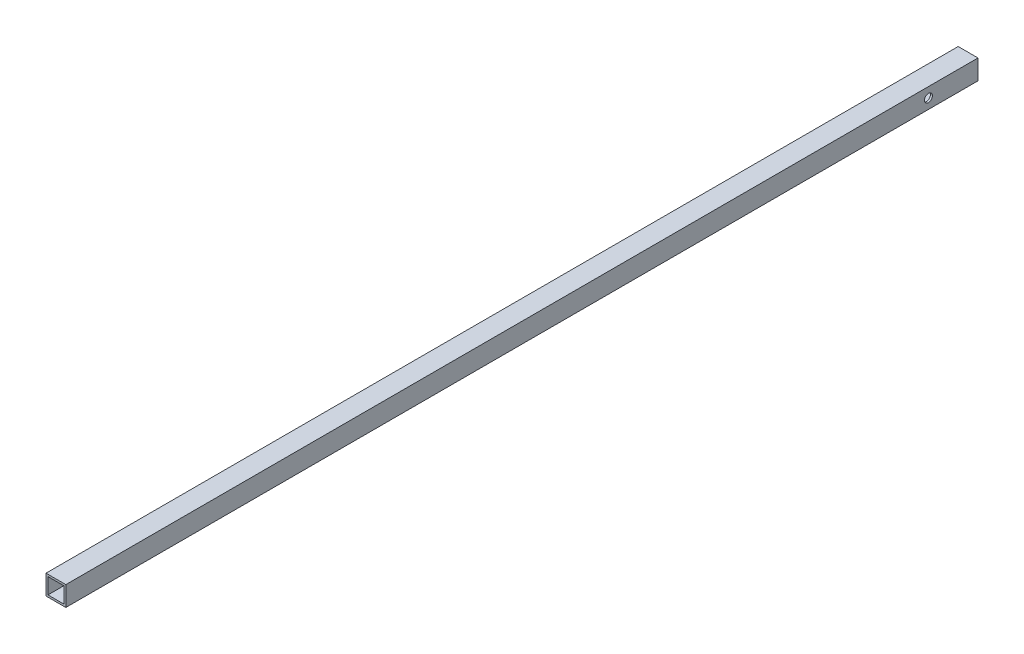
from build123d import *

# Parameters (mm, degrees)
SKETCH_1_W               = 20
SKETCH_1_H               = 20
SKETCH_1_W_2             = 16
SKETCH_1_H_2             = 16
EXTRUDE_1_DEPTH          = 970
SKETCH_2_R               = 4.05
CUT_EXTRUDE_1_DEPTH      = 970
SKETCH_4_W               = 21.376287738
SKETCH_4_H               = 29.089038522
CUT_EXTRUDE_3_DEPTH      = 50
SKETCH_6_R               = 1
CUT_EXTRUDE_5_DEPTH      = 10
M4X0_7_1_D               = 3.3
M4X0_7_1_DEPTH           = 5
M4X0_7_1_TIP             = 0.991420021
SKETCH_10_R              = 1
CUT_EXTRUDE_6_DEPTH      = 5
M4X0_7_4_D               = 3.3
M4X0_7_4_DEPTH           = 5
M4X0_7_4_TIP             = 0.991420021
M4X0_7_4_ON_FACE_2_D     = 3.3
M4X0_7_4_ON_FACE_2_DEPTH = 5
M4X0_7_4_ON_FACE_2_TIP   = 0.991420021
SKETCH_12_R              = 1
CUT_EXTRUDE_7_DEPTH      = 5
M4X0_7_5_D               = 3.3
M4X0_7_5_DEPTH           = 9
M4X0_7_5_TIP             = 0.991420021
M4X0_7_5_ON_FACE_2_D     = 3.3
M4X0_7_5_ON_FACE_2_DEPTH = 9
M4X0_7_5_ON_FACE_2_TIP   = 0.991420021


with BuildPart() as part:
    # ｽｹｯﾁ1 → ﾎﾞｽ - 押し出し1 (new body)
    with BuildSketch(Plane.XY):
        Rectangle(SKETCH_1_W, SKETCH_1_H)
        Rectangle(SKETCH_1_W_2, SKETCH_1_H_2, mode=Mode.SUBTRACT)
    extrude(amount=EXTRUDE_1_DEPTH)

    # ｽｹｯﾁ2 → ｶｯﾄ - 押し出し1 (cut)
    with BuildSketch(Plane(origin=(10, 0, 0), x_dir=(0, 0, -1), z_dir=(1, 0, 0))):
        with Locations((-50, 0)):
            Circle(SKETCH_2_R)
    extrude(amount=-CUT_EXTRUDE_1_DEPTH, mode=Mode.SUBTRACT)

    # ｽｹｯﾁ4 → ｶｯﾄ - 押し出し3 (cut)
    with BuildSketch(Plane.XY.offset(970)):
        Rectangle(SKETCH_4_W, SKETCH_4_H)
    extrude(amount=-CUT_EXTRUDE_3_DEPTH, mode=Mode.SUBTRACT)

    # ｽｹｯﾁ6 → ｶｯﾄ - 押し出し5 (cut)
    with BuildSketch(Plane.XZ.offset(10)):
        with Locations((0, 30)):
            Circle(SKETCH_6_R)
        with Locations((0, 50)):
            Circle(SKETCH_6_R)
    extrude(amount=-CUT_EXTRUDE_5_DEPTH, mode=Mode.SUBTRACT)

    # M4x0.7 ねじ穴1
    with Locations(Plane(origin=(0, -10, 30), x_dir=(0, 0, -1), z_dir=(0, -1, 0))):
        with Locations((0, 0), (-20, 0)):
            Hole(M4X0_7_1_D / 2, depth=M4X0_7_1_DEPTH)
            with Locations((0, 0, -(M4X0_7_1_DEPTH + M4X0_7_1_TIP / 2))):  # 118° drill point
                Cone(0, M4X0_7_1_D / 2, M4X0_7_1_TIP, mode=Mode.SUBTRACT)

    # ｽｹｯﾁ10 → ｶｯﾄ - 押し出し6 (cut)
    with BuildSketch(Plane(origin=(0, -10, 0), x_dir=(-1, 0, 0), z_dir=(0, -1, 0))):
        with Locations((0, -670)):
            Circle(SKETCH_10_R)
        with Locations((0, -650)):
            Circle(SKETCH_10_R)
    extrude(amount=-CUT_EXTRUDE_6_DEPTH, mode=Mode.SUBTRACT)

    # M4x0.7 ねじ穴4
    with Locations(Plane(origin=(0, -10, 650), x_dir=(0, 0, -1), z_dir=(0, -1, 0))):
        with Locations((0, 0)):
            Hole(M4X0_7_4_D / 2, depth=M4X0_7_4_DEPTH)
            with Locations((0, 0, -(M4X0_7_4_DEPTH + M4X0_7_4_TIP / 2))):  # 118° drill point
                Cone(0, M4X0_7_4_D / 2, M4X0_7_4_TIP, mode=Mode.SUBTRACT)

    # M4x0.7 ねじ穴4 on face 2
    with Locations(Plane(origin=(0, -8, 670), x_dir=(0, 0, -1), z_dir=(0, -1, 0))):
        with Locations((0, 0)):
            Hole(M4X0_7_4_ON_FACE_2_D / 2, depth=M4X0_7_4_ON_FACE_2_DEPTH)
            with Locations((0, 0, -(M4X0_7_4_ON_FACE_2_DEPTH + M4X0_7_4_ON_FACE_2_TIP / 2))):  # 118° drill point
                Cone(0, M4X0_7_4_ON_FACE_2_D / 2, M4X0_7_4_ON_FACE_2_TIP, mode=Mode.SUBTRACT)

    # ｽｹｯﾁ12 → ｶｯﾄ - 押し出し7 (cut)
    with BuildSketch(Plane.ZY.offset(10)):
        with Locations((710, 0)):
            Circle(SKETCH_12_R)
        with Locations((730, 0)):
            Circle(SKETCH_12_R)
        with Locations((40, 0)):
            Circle(SKETCH_12_R)
    extrude(amount=-CUT_EXTRUDE_7_DEPTH, mode=Mode.SUBTRACT)

    # M4x0.7 ねじ穴5
    with Locations(Plane(origin=(-10, 0, 730), x_dir=(0, 0, -1), z_dir=(-1, 0, 0))):
        with Locations((0, 0), (20, 0)):
            Hole(M4X0_7_5_D / 2, depth=M4X0_7_5_DEPTH)
            with Locations((0, 0, -(M4X0_7_5_DEPTH + M4X0_7_5_TIP / 2))):  # 118° drill point
                Cone(0, M4X0_7_5_D / 2, M4X0_7_5_TIP, mode=Mode.SUBTRACT)

    # M4x0.7 ねじ穴5 on face 2
    with Locations(Plane(origin=(-8, 0, 40), x_dir=(0, 0, -1), z_dir=(-1, 0, 0))):
        with Locations((0, 0)):
            Hole(M4X0_7_5_ON_FACE_2_D / 2, depth=M4X0_7_5_ON_FACE_2_DEPTH)
            with Locations((0, 0, -(M4X0_7_5_ON_FACE_2_DEPTH + M4X0_7_5_ON_FACE_2_TIP / 2))):  # 118° drill point
                Cone(0, M4X0_7_5_ON_FACE_2_D / 2, M4X0_7_5_ON_FACE_2_TIP, mode=Mode.SUBTRACT)


solid = part.part
